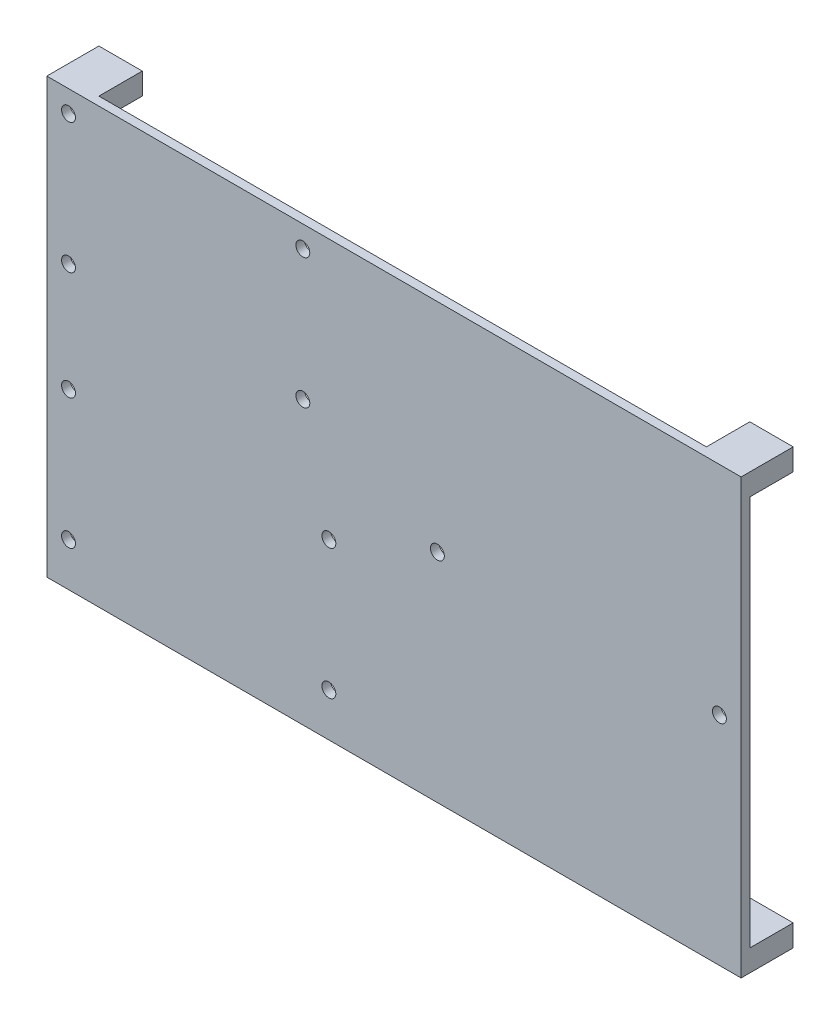
from build123d import *

# Parameters (mm, degrees)
SKETCH_1_W      = 160
SKETCH_1_H      = 100
SKETCH_1_R      = 1.6
EXTRUDE_1_DEPTH = 2
EXTRUDE_START   = -2
SKETCH_2_W      = 10
SKETCH_2_H      = 5
EXTRUDE_2_DEPTH = 10


with BuildPart() as part:
    # 草图1 → 凸台-拉伸1 (new body)
    with BuildSketch(Plane.XY):
        with Locations((19.466155548, -3.137913989)):
            Rectangle(SKETCH_1_W, SKETCH_1_H)
        with Locations((94.466155548, -3.137913989)):
            Circle(SKETCH_1_R, mode=Mode.SUBTRACT)
        with Locations((29.466155548, -3.137913989)):
            Circle(SKETCH_1_R, mode=Mode.SUBTRACT)
        with Locations((-55.533844452, -43.137913989)):
            Circle(SKETCH_1_R, mode=Mode.SUBTRACT)
        with Locations((-55.533844452, -13.137913989)):
            Circle(SKETCH_1_R, mode=Mode.SUBTRACT)
        with Locations((4.466155548, -13.137913989)):
            Circle(SKETCH_1_R, mode=Mode.SUBTRACT)
        with Locations((4.466155548, -43.137913989)):
            Circle(SKETCH_1_R, mode=Mode.SUBTRACT)
        with Locations((-55.533844452, 41.862086011)):
            Circle(SKETCH_1_R, mode=Mode.SUBTRACT)
        with Locations((-55.533844452, 11.862086011)):
            Circle(SKETCH_1_R, mode=Mode.SUBTRACT)
        with Locations((-1.533844452, 11.862086011)):
            Circle(SKETCH_1_R, mode=Mode.SUBTRACT)
        with Locations((-1.533844452, 41.862086011)):
            Circle(SKETCH_1_R, mode=Mode.SUBTRACT)
    extrude(amount=EXTRUDE_1_DEPTH)

    # 草图2 → 凸台-拉伸2 (add)
    with BuildSketch(Plane.XY.offset(2).offset(EXTRUDE_START)):
        with Locations((-55.533844452, 44.362086011)):
            Rectangle(SKETCH_2_W, SKETCH_2_H)
        with Locations((94.466155548, 44.362086011)):
            Rectangle(SKETCH_2_W, SKETCH_2_H)
        with Locations((94.466155548, -50.637913989)):
            Rectangle(SKETCH_2_W, SKETCH_2_H)
        with Locations((-55.533844452, -50.637913989)):
            Rectangle(SKETCH_2_W, SKETCH_2_H)
    extrude(amount=-EXTRUDE_2_DEPTH)


solid = part.part
